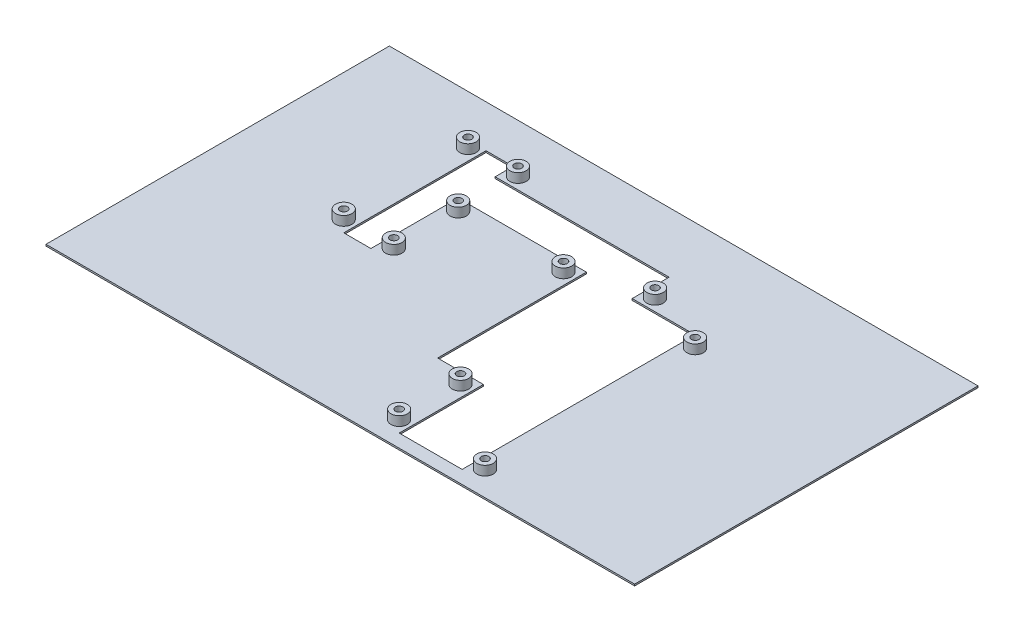
from build123d import *

# Parameters (mm, degrees)
SKETCH1_W           = 360
SKETCH1_H           = 210
BOSS_EXTRUDE1_DEPTH = 1
SKETCH2_R           = 5
SKETCH2_R_2         = 2.3
BOSS_EXTRUDE2_DEPTH = 5.7


with BuildPart() as part:
    # Sketch1 → Boss-Extrude1 (new body)
    with BuildSketch(Plane(origin=(0, 0, 0), x_dir=(1, 0, 0), z_dir=(0, 1, 0))):
        Rectangle(SKETCH1_W, SKETCH1_H)
        Polygon((28, -45.5), (0, -45.5), (0, 45.5), (-78.4, 45.5), (-78.4, -7.9), (-95, -7.9), (-95, 79.1), (-78.4, 79.1), (-78.4, 68.1), (28, 68.1), (28, 45.5), (66.5, 45.5), (66.5, -45.5), (66.5, -97), (28, -97), align=None, mode=Mode.SUBTRACT)
    extrude(amount=BOSS_EXTRUDE1_DEPTH)

    # Sketch2 → Boss-Extrude2 (add)
    with BuildSketch(Plane(origin=(0, 1, 0), x_dir=(1, 0, 0), z_dir=(0, 1, 0))):
        with Locations((-71.4, 75.1)):
            Circle(SKETCH2_R)
        with Locations((-71.4, 75.1)):
            Circle(SKETCH2_R_2, mode=Mode.SUBTRACT)
        with Locations((-71.4, 38.5)):
            Circle(SKETCH2_R)
        with Locations((-71.4, 38.5)):
            Circle(SKETCH2_R_2, mode=Mode.SUBTRACT)
        with Locations((-102, 75.1)):
            Circle(SKETCH2_R)
        with Locations((-102, 75.1)):
            Circle(SKETCH2_R_2, mode=Mode.SUBTRACT)
        with Locations((-7, 38.5)):
            Circle(SKETCH2_R)
        with Locations((-7, 38.5)):
            Circle(SKETCH2_R_2, mode=Mode.SUBTRACT)
        with Locations((35, 52.5)):
            Circle(SKETCH2_R)
        with Locations((35, 52.5)):
            Circle(SKETCH2_R_2, mode=Mode.SUBTRACT)
        with Locations((21, -52.5)):
            Circle(SKETCH2_R)
        with Locations((21, -52.5)):
            Circle(SKETCH2_R_2, mode=Mode.SUBTRACT)
        with Locations((-71.4, -0.9)):
            Circle(SKETCH2_R)
        with Locations((-71.4, -0.9)):
            Circle(SKETCH2_R_2, mode=Mode.SUBTRACT)
        with Locations((-102, -0.9)):
            Circle(SKETCH2_R)
        with Locations((-102, -0.9)):
            Circle(SKETCH2_R_2, mode=Mode.SUBTRACT)
        with Locations((73.5, 38.5)):
            Circle(SKETCH2_R)
        with Locations((73.5, 38.5)):
            Circle(SKETCH2_R_2, mode=Mode.SUBTRACT)
        with Locations((73.5, -90)):
            Circle(SKETCH2_R)
        with Locations((73.5, -90)):
            Circle(SKETCH2_R_2, mode=Mode.SUBTRACT)
        with Locations((21, -90)):
            Circle(SKETCH2_R)
        with Locations((21, -90)):
            Circle(SKETCH2_R_2, mode=Mode.SUBTRACT)
    extrude(amount=BOSS_EXTRUDE2_DEPTH)


solid = part.part
